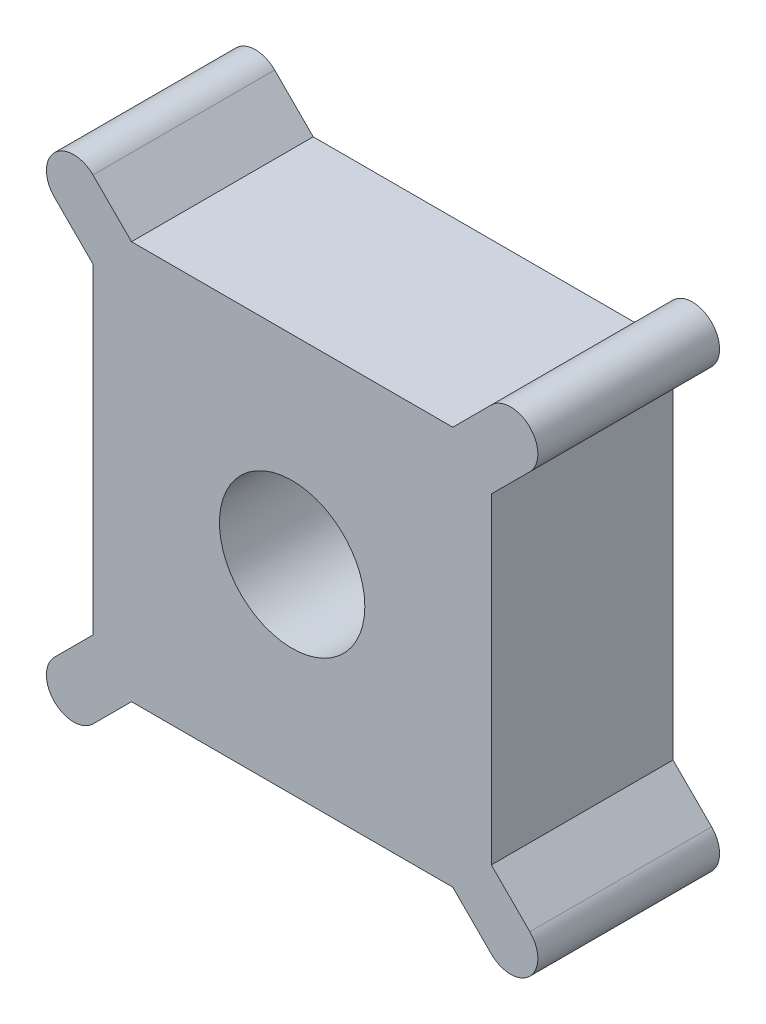
from build123d import *

# Parameters (mm, degrees)
BOSS_EXTRUDE1_DEPTH = 10
SKETCH4_R           = 4
CUT_EXTRUDE1_DEPTH  = 11


with BuildPart() as part:
    # Sketch3 → Boss-Extrude1 (new body)
    with BuildSketch(Plane.XY):
        with BuildLine():
            Line((-13.081475452, 10.960155108), (-10.960155108, 8.838834765))
            Line((-10.960155108, 8.838834765), (-10.960155108, -8.838834765))
            Line((-10.960155108, -8.838834765), (-13.081475452, -10.960155108))
            ThreePointArc((-13.081475452, -10.960155108), (-13.081475452, -13.081475452), (-10.960155108, -13.081475452))
            Line((-10.960155108, -13.081475452), (-8.838834765, -10.960155108))
            Line((-8.838834765, -10.960155108), (8.838834765, -10.960155108))
            Line((8.838834765, -10.960155108), (10.960155108, -13.081475452))
            ThreePointArc((10.960155108, -13.081475452), (13.081475452, -13.081475452), (13.081475452, -10.960155108))
            Line((13.081475452, -10.960155108), (10.960155108, -8.838834765))
            Line((10.960155108, -8.838834765), (10.960155108, 8.838834765))
            Line((10.960155108, 8.838834765), (13.081475452, 10.960155108))
            ThreePointArc((13.081475452, 10.960155108), (13.081475452, 13.081475452), (10.960155108, 13.081475452))
            Line((10.960155108, 13.081475452), (8.838834765, 10.960155108))
            Line((8.838834765, 10.960155108), (-8.838834765, 10.960155108))
            Line((-8.838834765, 10.960155108), (-10.960155108, 13.081475452))
            ThreePointArc((-10.960155108, 13.081475452), (-13.081475452, 13.081475452), (-13.081475452, 10.960155108))
        make_face()
    extrude(amount=-BOSS_EXTRUDE1_DEPTH)

    # Sketch4 → Cut-Extrude1 (cut, through all)
    with BuildSketch(Plane.XY):
        Circle(SKETCH4_R)
    extrude(amount=-CUT_EXTRUDE1_DEPTH, mode=Mode.SUBTRACT)


solid = part.part
